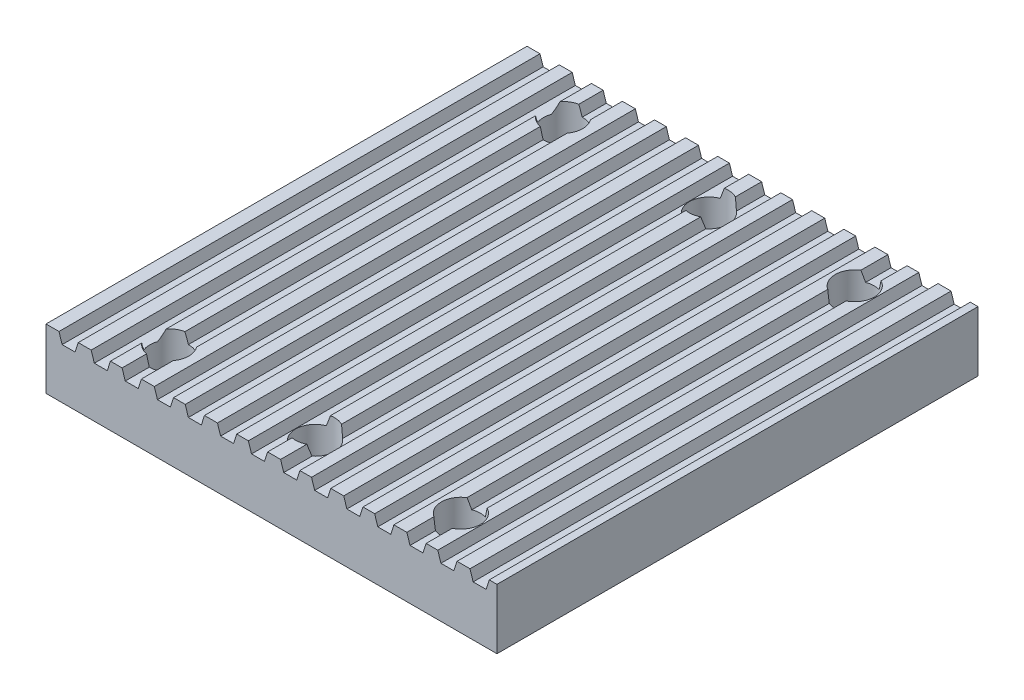
from build123d import *

# Parameters (mm, degrees)
SKETCH1_W               = 1500
SKETCH1_H               = 1600
SKETCH1_R               = 65
BOSS_EXTRUDE1_DEPTH     = 200
CUT_EXTRUDE1_DEPTH      = 1
CUT_EXTRUDE1_DEPTH_BACK = 1601


with BuildPart() as part:
    # Sketch1 → Boss-Extrude1 (new body)
    with BuildSketch(Plane(origin=(0, 0, 0), x_dir=(1, 0, 0), z_dir=(0, 1, 0))):
        with Locations((-48.109243697, 800)):
            Rectangle(SKETCH1_W, SKETCH1_H)
        with Locations((436.890756303, 1455)):
            Circle(SKETCH1_R, mode=Mode.SUBTRACT)
        with Locations((-48.109243697, 1455)):
            Circle(SKETCH1_R, mode=Mode.SUBTRACT)
        with Locations((-533.109243697, 1455)):
            Circle(SKETCH1_R, mode=Mode.SUBTRACT)
        with Locations((436.890756303, 145)):
            Circle(SKETCH1_R, mode=Mode.SUBTRACT)
        with Locations((-48.109243697, 145)):
            Circle(SKETCH1_R, mode=Mode.SUBTRACT)
        with Locations((-533.109243697, 145)):
            Circle(SKETCH1_R, mode=Mode.SUBTRACT)
    extrude(amount=BOSS_EXTRUDE1_DEPTH)

    # Sketch3 → Cut-Extrude1 (cut, two sides)
    with BuildSketch(Plane.XY) as cut_extrude1_sk:
        Polygon((-690.966386555, 200), (-754.956850499, 200), (-744.537815126, 167.358848998), (-701.385421928, 167.358848998), align=None)
        Polygon((676.176470588, 200), (612.186006644, 200), (622.605042017, 167.358848998), (665.757435215, 167.358848998), align=None)
        Polygon((569.033613445, 200), (505.043149501, 200), (515.462184874, 167.358848998), (558.614578072, 167.358848998), align=None)
        Polygon((466.176470588, 200), (402.186006644, 200), (412.605042017, 167.358848998), (455.757435215, 167.358848998), align=None)
        Polygon((359.033613445, 200), (295.043149501, 200), (305.462184874, 167.358848998), (348.614578072, 167.358848998), align=None)
        Polygon((256.176470588, 200), (192.186006644, 200), (202.605042017, 167.358848998), (245.757435215, 167.358848998), align=None)
        Polygon((149.033613445, 200), (85.043149501, 200), (95.462184874, 167.358848998), (138.614578072, 167.358848998), align=None)
        Polygon((46.176470588, 200), (-17.813993356, 200), (-7.394957983, 167.358848998), (35.757435215, 167.358848998), align=None)
        Polygon((-60.966386555, 200), (-124.956850499, 200), (-114.537815126, 167.358848998), (-71.385421928, 167.358848998), align=None)
        Polygon((-163.823529412, 200), (-227.813993356, 200), (-217.394957983, 167.358848998), (-174.242564785, 167.358848998), align=None)
        Polygon((-270.966386555, 200), (-334.956850499, 200), (-324.537815126, 167.358848998), (-281.385421928, 167.358848998), align=None)
        Polygon((-373.823529412, 200), (-437.813993356, 200), (-427.394957983, 167.358848998), (-384.242564785, 167.358848998), align=None)
        Polygon((-480.966386555, 200), (-544.956850499, 200), (-534.537815126, 167.358848998), (-491.385421928, 167.358848998), align=None)
        Polygon((-583.823529412, 200), (-647.813993356, 200), (-637.394957983, 167.358848998), (-594.242564785, 167.358848998), align=None)
    extrude(amount=CUT_EXTRUDE1_DEPTH, mode=Mode.SUBTRACT)
    extrude(cut_extrude1_sk.sketch, amount=-CUT_EXTRUDE1_DEPTH_BACK, mode=Mode.SUBTRACT)


solid = part.part
